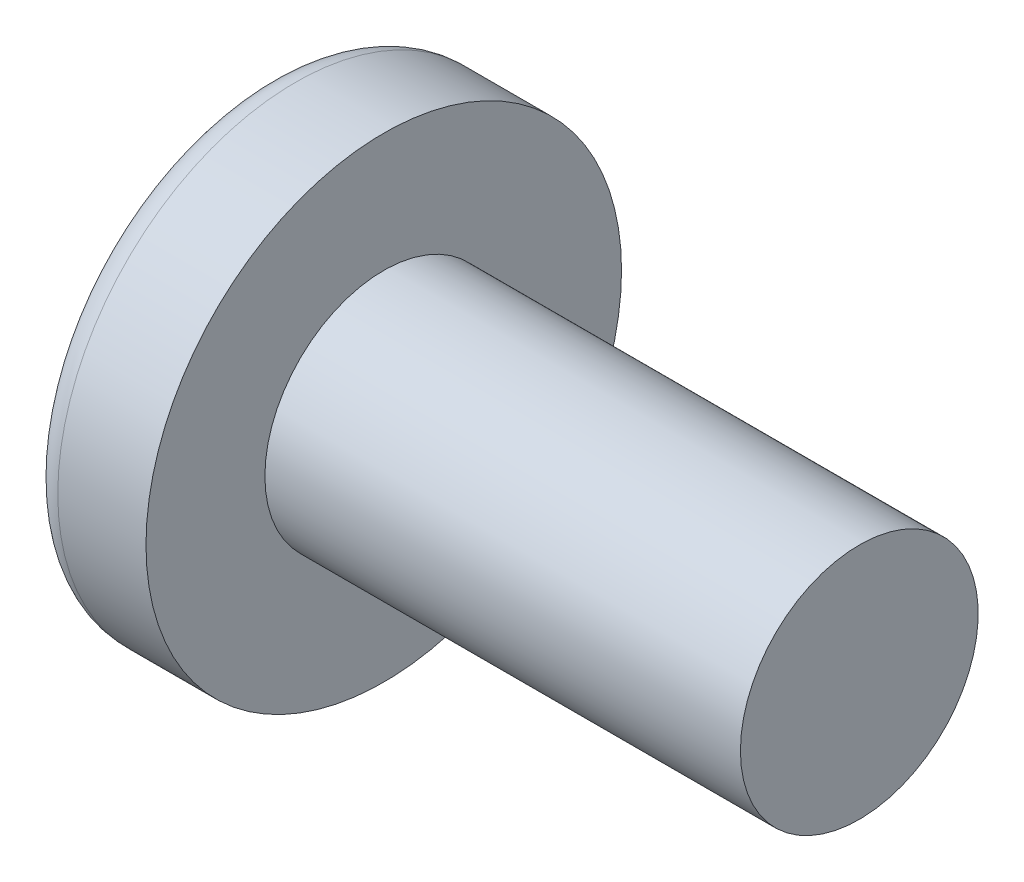
from build123d import *

# Parameters (mm, degrees)
SKETCH3_W         = 0.93
SKETCH3_H         = 4.4
SKETCH4_W         = 0.465
SKETCH4_H         = 0.465
CIRPATTERN1_COUNT = 2
CIRPATTERN1_ANGLE = 90


with BuildPart() as part:
    # BodySke → Base-Revolve (revolve)
    with BuildSketch(Plane.XY):
        with BuildLine():
            Line((3.1, 2), (3.1, 4))
            Line((3.1, 4), (1.616353821, 4))
            ThreePointArc((1.616353821, 4), (1.397629036, 3.947269784), (1.226960106, 3.800664452))
            ThreePointArc((1.226960106, 3.800664452), (0.314340807, 1.996902688), (0, 0))
            Line((0, 0), (11.1, 0))
            Line((11.1, 0), (11.1, 2))
            Line((11.1, 2), (3.1, 2))
        make_face()
    revolve(axis=Axis((-25.4, 0, 0), (1, 0, 0)))

    # Sketch3 → Cut-Loft1 section 0
    with BuildSketch(Plane(origin=(0, 0, 0), x_dir=(0, 0, -1), z_dir=(1, 0, 0))):
        Rectangle(SKETCH3_W, SKETCH3_H)
    # Sketch4 → Cut-Loft1 section 1
    with BuildSketch(Plane(origin=(2.45, 0, 0), x_dir=(0, 0, -1), z_dir=(1, 0, 0))):
        Rectangle(SKETCH4_W, SKETCH4_H)
    cut_loft1 = loft(mode=Mode.SUBTRACT)

    # CirPattern1: Cut-Loft1 ×2 about axis
    cirpattern1_axis = Axis((0, 0, 0), (1, 0, 0))
    for i in range(1, CIRPATTERN1_COUNT):
        add(cut_loft1.rotate(cirpattern1_axis, i * CIRPATTERN1_ANGLE / (CIRPATTERN1_COUNT - 1)), mode=Mode.SUBTRACT)


solid = part.part
